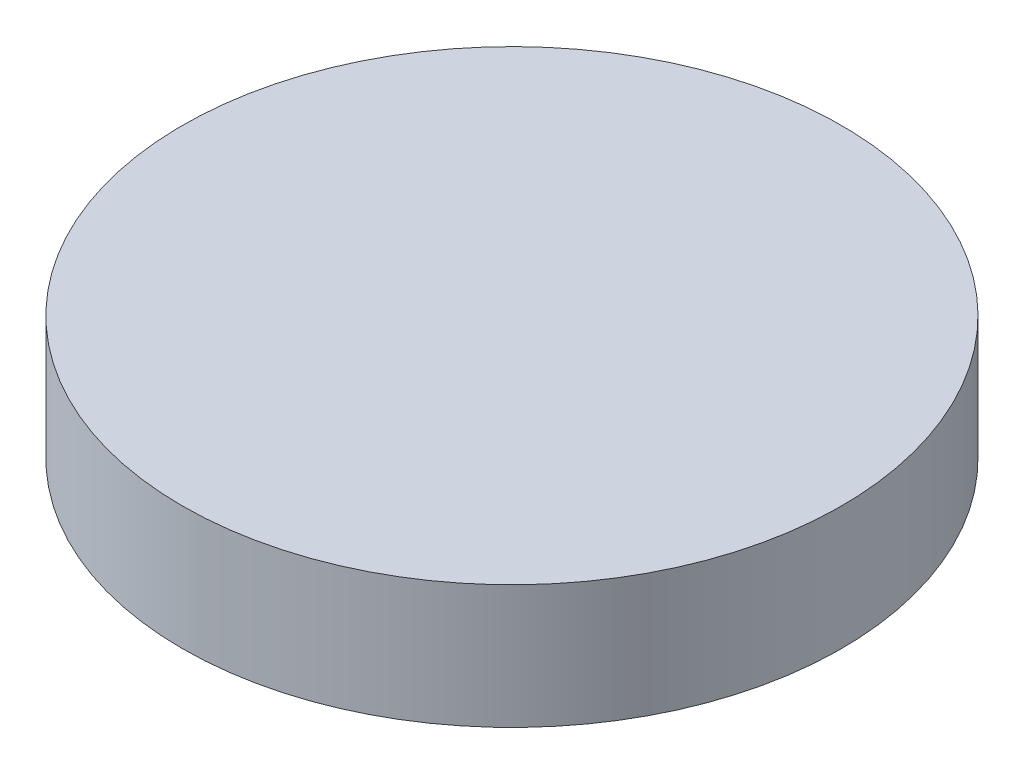
from build123d import *

# Parameters (mm, degrees)
SKETCH1_R           = 20
BOSS_EXTRUDE1_DEPTH = 7.5


with BuildPart() as part:
    # Sketch1 → Boss-Extrude1 (new body)
    with BuildSketch(Plane(origin=(0, 0, 0), x_dir=(1, 0, 0), z_dir=(0, 1, 0))):
        Circle(SKETCH1_R)
    extrude(amount=BOSS_EXTRUDE1_DEPTH)


solid = part.part
